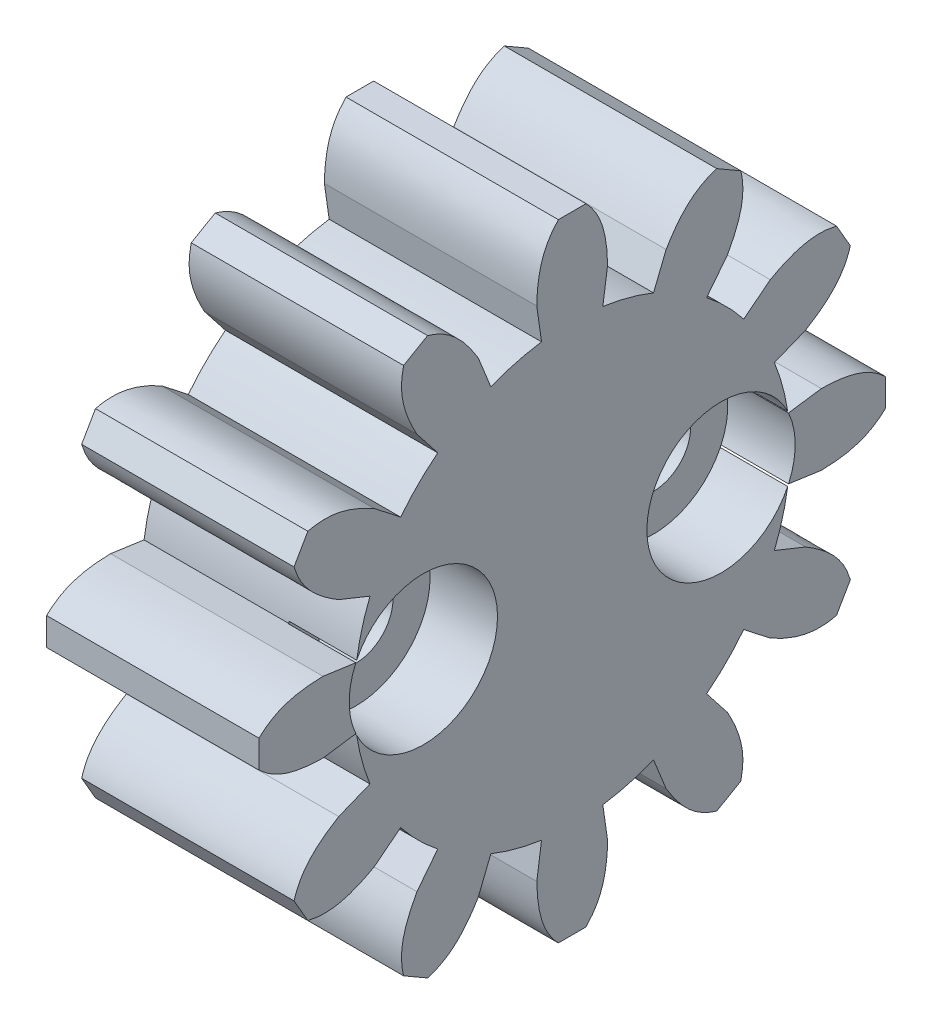
from build123d import *

# Parameters (mm, degrees)
BOSS_EXTRUDE1_DEPTH = 6.3
SKETCH2_R           = 1.1
CUT_EXTRUDE1_DEPTH  = 7.3000001
SKETCH3_R           = 2.2
CUT_EXTRUDE2_DEPTH  = 2


with BuildPart() as part:
    # Sketch1 → Boss-Extrude1 (new body)
    with BuildSketch(Plane(origin=(0, 0, 0), x_dir=(0, 0, -1), z_dir=(1, 0, 0))):
        with BuildLine():
            Line((-0.909343603, 6.400728022), (-1.05, 7.390786494))
            add(Edge.make_bspline(
                [(-0.410905417, 9.290786494), (-0.761226832, 8.915917898), (-1.03420339, 8.440297341), (-1.05, 7.390786494)],
                knots=[0, 0, 0, 0, 1, 1, 1, 1], degree=3))
            Line((-0.410905417, 9.290786494), (0.410905417, 9.290786494))
            add(Edge.make_bspline(
                [(0.410905417, 9.290786494), (0.761226832, 8.915917898), (1.03420339, 8.440297341), (1.05, 7.390786494)],
                knots=[0, 0, 0, 0, 1, 1, 1, 1], degree=3))
            Line((1.05, 7.390786494), (0.909343603, 6.400728022))
            ThreePointArc((0.909343603, 6.400728022), (1.673265127, 6.244710467), (2.41284935, 5.997864871))
            Line((2.41284935, 5.997864871), (2.786066573, 6.925608858))
            add(Edge.make_bspline(
                [(4.289538717, 8.251509833), (3.798717175, 8.102024814), (3.324502262, 7.826613608), (2.786066573, 6.925608858)],
                knots=[0, 0, 0, 0, 1, 1, 1, 1], degree=3))
            Line((4.289538717, 8.251509833), (5.001247777, 7.840604417))
            add(Edge.make_bspline(
                [(5.001247777, 7.840604417), (5.117200723, 7.340797982), (5.115795079, 6.792410217), (4.604719921, 5.875608858)],
                knots=[0, 0, 0, 0, 1, 1, 1, 1], degree=3))
            Line((4.604719921, 5.875608858), (3.987878672, 5.088521268))
            ThreePointArc((3.987878672, 5.088521268), (4.57144534, 4.57144534), (5.088521268, 3.987878672))
            Line((5.088521268, 3.987878672), (5.875608858, 4.604719921))
            add(Edge.make_bspline(
                [(7.840604417, 5.001247777), (7.340797982, 5.117200723), (6.792410217, 5.115795079), (5.875608858, 4.604719921)],
                knots=[0, 0, 0, 0, 1, 1, 1, 1], degree=3))
            Line((7.840604417, 5.001247777), (8.251509833, 4.289538717))
            add(Edge.make_bspline(
                [(8.251509833, 4.289538717), (8.102024814, 3.798717175), (7.826613608, 3.324502262), (6.925608858, 2.786066573)],
                knots=[0, 0, 0, 0, 1, 1, 1, 1], degree=3))
            Line((6.925608858, 2.786066573), (5.997864871, 2.41284935))
            ThreePointArc((5.997864871, 2.41284935), (6.244710467, 1.673265127), (6.400728022, 0.909343603))
            Line((6.400728022, 0.909343603), (7.390786494, 1.05))
            add(Edge.make_bspline(
                [(9.290786494, 0.410905417), (8.915917898, 0.761226832), (8.440297341, 1.03420339), (7.390786494, 1.05)],
                knots=[0, 0, 0, 0, 1, 1, 1, 1], degree=3))
            Line((9.290786494, 0.410905417), (9.290786494, -0.410905417))
            add(Edge.make_bspline(
                [(9.290786494, -0.410905417), (8.915917898, -0.761226832), (8.440297341, -1.03420339), (7.390786494, -1.05)],
                knots=[0, 0, 0, 0, 1, 1, 1, 1], degree=3))
            Line((7.390786494, -1.05), (6.400728022, -0.909343603))
            ThreePointArc((6.400728022, -0.909343603), (6.244710467, -1.673265127), (5.997864871, -2.41284935))
            Line((5.997864871, -2.41284935), (6.925608858, -2.786066573))
            add(Edge.make_bspline(
                [(8.251509833, -4.289538717), (8.102024814, -3.798717175), (7.826613608, -3.324502262), (6.925608858, -2.786066573)],
                knots=[0, 0, 0, 0, 1, 1, 1, 1], degree=3))
            Line((8.251509833, -4.289538717), (7.840604417, -5.001247777))
            add(Edge.make_bspline(
                [(7.840604417, -5.001247777), (7.340797982, -5.117200723), (6.792410217, -5.115795079), (5.875608858, -4.604719921)],
                knots=[0, 0, 0, 0, 1, 1, 1, 1], degree=3))
            Line((5.875608858, -4.604719921), (5.088521268, -3.987878672))
            ThreePointArc((5.088521268, -3.987878672), (4.57144534, -4.57144534), (3.987878672, -5.088521268))
            Line((3.987878672, -5.088521268), (4.604719921, -5.875608858))
            add(Edge.make_bspline(
                [(5.001247777, -7.840604417), (5.117200723, -7.340797982), (5.115795079, -6.792410217), (4.604719921, -5.875608858)],
                knots=[0, 0, 0, 0, 1, 1, 1, 1], degree=3))
            Line((5.001247777, -7.840604417), (4.289538717, -8.251509833))
            add(Edge.make_bspline(
                [(4.289538717, -8.251509833), (3.798717175, -8.102024814), (3.324502262, -7.826613608), (2.786066573, -6.925608858)],
                knots=[0, 0, 0, 0, 1, 1, 1, 1], degree=3))
            Line((2.786066573, -6.925608858), (2.41284935, -5.997864871))
            ThreePointArc((2.41284935, -5.997864871), (1.673265127, -6.244710467), (0.909343603, -6.400728022))
            Line((0.909343603, -6.400728022), (1.05, -7.390786494))
            add(Edge.make_bspline(
                [(0.410905417, -9.290786494), (0.761226832, -8.915917898), (1.03420339, -8.440297341), (1.05, -7.390786494)],
                knots=[0, 0, 0, 0, 1, 1, 1, 1], degree=3))
            Line((0.410905417, -9.290786494), (-0.410905417, -9.290786494))
            add(Edge.make_bspline(
                [(-0.410905417, -9.290786494), (-0.761226832, -8.915917898), (-1.03420339, -8.440297341), (-1.05, -7.390786494)],
                knots=[0, 0, 0, 0, 1, 1, 1, 1], degree=3))
            Line((-1.05, -7.390786494), (-0.909343603, -6.400728022))
            ThreePointArc((-0.909343603, -6.400728022), (-1.673265127, -6.244710467), (-2.41284935, -5.997864871))
            Line((-2.41284935, -5.997864871), (-2.786066573, -6.925608858))
            add(Edge.make_bspline(
                [(-4.289538717, -8.251509833), (-3.798717175, -8.102024814), (-3.324502262, -7.826613608), (-2.786066573, -6.925608858)],
                knots=[0, 0, 0, 0, 1, 1, 1, 1], degree=3))
            Line((-4.289538717, -8.251509833), (-5.001247777, -7.840604417))
            add(Edge.make_bspline(
                [(-5.001247777, -7.840604417), (-5.117200723, -7.340797982), (-5.115795079, -6.792410217), (-4.604719921, -5.875608858)],
                knots=[0, 0, 0, 0, 1, 1, 1, 1], degree=3))
            Line((-4.604719921, -5.875608858), (-3.987878672, -5.088521268))
            ThreePointArc((-3.987878672, -5.088521268), (-4.57144534, -4.57144534), (-5.088521268, -3.987878672))
            Line((-5.088521268, -3.987878672), (-5.875608858, -4.604719921))
            add(Edge.make_bspline(
                [(-7.840604417, -5.001247777), (-7.340797982, -5.117200723), (-6.792410217, -5.115795079), (-5.875608858, -4.604719921)],
                knots=[0, 0, 0, 0, 1, 1, 1, 1], degree=3))
            Line((-7.840604417, -5.001247777), (-8.251509833, -4.289538717))
            add(Edge.make_bspline(
                [(-8.251509833, -4.289538717), (-8.102024814, -3.798717175), (-7.826613608, -3.324502262), (-6.925608858, -2.786066573)],
                knots=[0, 0, 0, 0, 1, 1, 1, 1], degree=3))
            Line((-6.925608858, -2.786066573), (-5.997864871, -2.41284935))
            ThreePointArc((-5.997864871, -2.41284935), (-6.244710467, -1.673265127), (-6.400728022, -0.909343603))
            Line((-6.400728022, -0.909343603), (-7.390786494, -1.05))
            add(Edge.make_bspline(
                [(-9.290786494, -0.410905417), (-8.915917898, -0.761226832), (-8.440297341, -1.03420339), (-7.390786494, -1.05)],
                knots=[0, 0, 0, 0, 1, 1, 1, 1], degree=3))
            Line((-9.290786494, -0.410905417), (-9.290786494, 0.410905417))
            add(Edge.make_bspline(
                [(-9.290786494, 0.410905417), (-8.915917898, 0.761226832), (-8.440297341, 1.03420339), (-7.390786494, 1.05)],
                knots=[0, 0, 0, 0, 1, 1, 1, 1], degree=3))
            Line((-7.390786494, 1.05), (-6.400728022, 0.909343603))
            ThreePointArc((-6.400728022, 0.909343603), (-6.244710467, 1.673265127), (-5.997864871, 2.41284935))
            Line((-5.997864871, 2.41284935), (-6.925608858, 2.786066573))
            add(Edge.make_bspline(
                [(-8.251509833, 4.289538717), (-8.102024814, 3.798717175), (-7.826613608, 3.324502262), (-6.925608858, 2.786066573)],
                knots=[0, 0, 0, 0, 1, 1, 1, 1], degree=3))
            Line((-8.251509833, 4.289538717), (-7.840604417, 5.001247777))
            add(Edge.make_bspline(
                [(-7.840604417, 5.001247777), (-7.340797982, 5.117200723), (-6.792410217, 5.115795079), (-5.875608858, 4.604719921)],
                knots=[0, 0, 0, 0, 1, 1, 1, 1], degree=3))
            Line((-5.875608858, 4.604719921), (-5.088521268, 3.987878672))
            ThreePointArc((-5.088521268, 3.987878672), (-4.57144534, 4.57144534), (-3.987878672, 5.088521268))
            Line((-3.987878672, 5.088521268), (-4.604719921, 5.875608858))
            add(Edge.make_bspline(
                [(-5.001247777, 7.840604417), (-5.117200723, 7.340797982), (-5.115795079, 6.792410217), (-4.604719921, 5.875608858)],
                knots=[0, 0, 0, 0, 1, 1, 1, 1], degree=3))
            Line((-5.001247777, 7.840604417), (-4.289538717, 8.251509833))
            add(Edge.make_bspline(
                [(-4.289538717, 8.251509833), (-3.798717175, 8.102024814), (-3.324502262, 7.826613608), (-2.786066573, 6.925608858)],
                knots=[0, 0, 0, 0, 1, 1, 1, 1], degree=3))
            Line((-2.786066573, 6.925608858), (-2.41284935, 5.997864871))
            ThreePointArc((-2.41284935, 5.997864871), (-1.673265127, 6.244710467), (-0.909343603, 6.400728022))
        make_face()
    extrude(amount=BOSS_EXTRUDE1_DEPTH)

    # Sketch2 → Cut-Extrude1 (cut, through all)
    with BuildSketch(Plane(origin=(6.3, 0, 0), x_dir=(0, 0, -1), z_dir=(1, 0, 0))):
        with Locations((4.415267157, 0)):
            Circle(SKETCH2_R)
        with Locations((-4.415267157, 0)):
            Circle(SKETCH2_R)
    extrude(amount=-CUT_EXTRUDE1_DEPTH, mode=Mode.SUBTRACT)

    # Sketch3 → Cut-Extrude2 (cut)
    with BuildSketch(Plane(origin=(6.3, 0, 0), x_dir=(0, 0, -1), z_dir=(1, 0, 0))):
        with Locations((-4.415267157, 0)):
            Circle(SKETCH3_R)
        with Locations((4.415267157, 0)):
            Circle(SKETCH3_R)
    extrude(amount=-CUT_EXTRUDE2_DEPTH, mode=Mode.SUBTRACT)


solid = part.part
